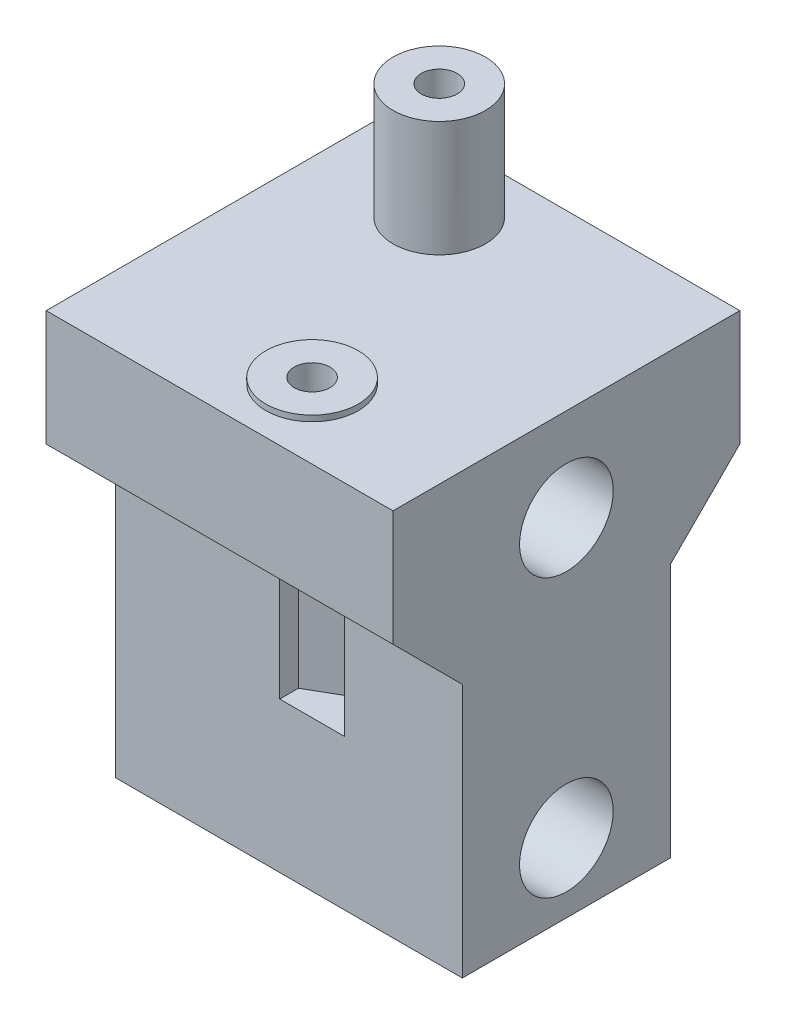
from build123d import *

# Parameters (mm, degrees)
SKETCH_1_W           = 30
SKETCH_1_H           = 30
EXTRUDE_1_DEPTH      = 38
SKETCH_3_R           = 4
EXTRUDE_3_DEPTH      = 10
SKETCH_7_R           = 4
EXTRUDE_4_DEPTH      = 0.5
SKETCH_6_R           = 4.05
CUT_EXTRUDE_3_DEPTH  = 31
SKETCH_9_R           = 1.55
CUT_EXTRUDE_4_DEPTH  = 21
CUT_EXTRUDE_6_DEPTH  = 31
CUT_EXTRUDE_5_DEPTH  = 15
SKETCH_12_W          = 4.9
SKETCH_12_H          = 15
EXTRUDE_5_DEPTH      = 7
SKETCH_14_W          = 0.3
SKETCH_14_H          = 13
CUT_EXTRUDE_7_DEPTH  = 5
SKETCH_15_R          = 1
CUT_EXTRUDE_8_DEPTH  = 24.7
CUT_EXTRUDE_10_DEPTH = 1.8


with BuildPart() as part:
    # 草图1 → 凸台-拉伸1 (new body)
    with BuildSketch(Plane(origin=(0, 0, 0), x_dir=(1, 0, 0), z_dir=(0, 1, 0))):
        with Locations((15, 15)):
            Rectangle(SKETCH_1_W, SKETCH_1_H)
    extrude(amount=EXTRUDE_1_DEPTH)

    # 草图3 → 凸台-拉伸3 (add)
    with BuildSketch(Plane(origin=(0, 38, -50), x_dir=(1, 0, 0), z_dir=(0, -1, 0))):
        with Locations((10, 26)):
            Circle(SKETCH_3_R)
    extrude(amount=-EXTRUDE_3_DEPTH)

    # 草图7 → 凸台-拉伸4 (add)
    with BuildSketch(Plane.XZ.offset(-38)):
        with Locations((17, -6)):
            Circle(SKETCH_7_R)
    extrude(amount=-EXTRUDE_4_DEPTH)

    # 草图6 → 切除-拉伸3 (cut, through all)
    with BuildSketch(Plane(origin=(30, 0, 0), x_dir=(0, 0, -1), z_dir=(1, 0, 0))):
        with Locations((15, 6)):
            Circle(SKETCH_6_R)
        with Locations((15, 30)):
            Circle(SKETCH_6_R)
    extrude(amount=-CUT_EXTRUDE_3_DEPTH, mode=Mode.SUBTRACT)

    # 草图9 → 切除-拉伸4 (cut, through all)
    with BuildSketch(Plane(origin=(0, 28, 0), x_dir=(1, 0, 0), z_dir=(0, 1, 0))):
        with Locations((17, 6)):
            Circle(SKETCH_9_R)
        with Locations((10, 24)):
            Circle(SKETCH_9_R)
    extrude(amount=CUT_EXTRUDE_4_DEPTH, mode=Mode.SUBTRACT)

    # 草图11 → 切除-拉伸6 (cut, through all)
    with BuildSketch(Plane(origin=(30, 0, 0), x_dir=(0, 0, -1), z_dir=(1, 0, 0))):
        Polygon((6, 0), (6, 22), (0, 28), (0, 0), align=None)
        Polygon((24, 0), (24, 22), (30, 28), (30, 0), align=None)
    extrude(amount=-CUT_EXTRUDE_6_DEPTH, mode=Mode.SUBTRACT)

    # 草图10 → 切除-拉伸5 (cut)
    with BuildSketch(Plane(origin=(0, 28, 0), x_dir=(1, 0, 0), z_dir=(0, 1, 0))):
        Polygon((19.8, 0), (19.8, 7.616580754), (17, 9.233161507), (14.2, 7.616580754), (14.2, 0), align=None)
        Polygon((10, 20.766838493), (12.8, 22.383419246), (12.8, 30), (7.2, 30), (7.2, 22.383419246), align=None)
    extrude(amount=-CUT_EXTRUDE_5_DEPTH, mode=Mode.SUBTRACT)

    # 草图12 → 凸台-拉伸5 (add)
    with BuildSketch(Plane.ZY):
        with Locations((-21.55, 7.5)):
            Rectangle(SKETCH_12_W, SKETCH_12_H)
    extrude(amount=EXTRUDE_5_DEPTH)

    # 草图14 → 切除-拉伸7 (cut)
    with BuildSketch(Plane.ZY.offset(7)):
        with Locations((-23.85, 8.5)):
            Rectangle(SKETCH_14_W, SKETCH_14_H)
    extrude(amount=-CUT_EXTRUDE_7_DEPTH, mode=Mode.SUBTRACT)

    # 草图15 → 切除-拉伸8 (cut, through all)
    with BuildSketch(Plane(origin=(0, 0, -23.7), x_dir=(-1, 0, 0), z_dir=(0, 0, -1))):
        with Locations((4, 12)):
            Circle(SKETCH_15_R)
        with Locations((4, 5.5)):
            Circle(SKETCH_15_R)
    extrude(amount=-CUT_EXTRUDE_8_DEPTH, mode=Mode.SUBTRACT)

    # 草图17 → 切除-拉伸10 (cut)
    with BuildSketch(Plane.XY.offset(-19.1)):
        Polygon((-1.95, 10.816431948), (-1.95, 13.183568052), (-4, 14.367136104), (-6.05, 13.183568052), (-6.05, 10.816431948), (-4, 9.632863896), align=None)
        Polygon((-1.95, 4.316431948), (-1.95, 6.683568052), (-4, 7.867136104), (-6.05, 6.683568052), (-6.05, 4.316431948), (-4, 3.132863896), align=None)
    extrude(amount=-CUT_EXTRUDE_10_DEPTH, mode=Mode.SUBTRACT)


solid = part.part
